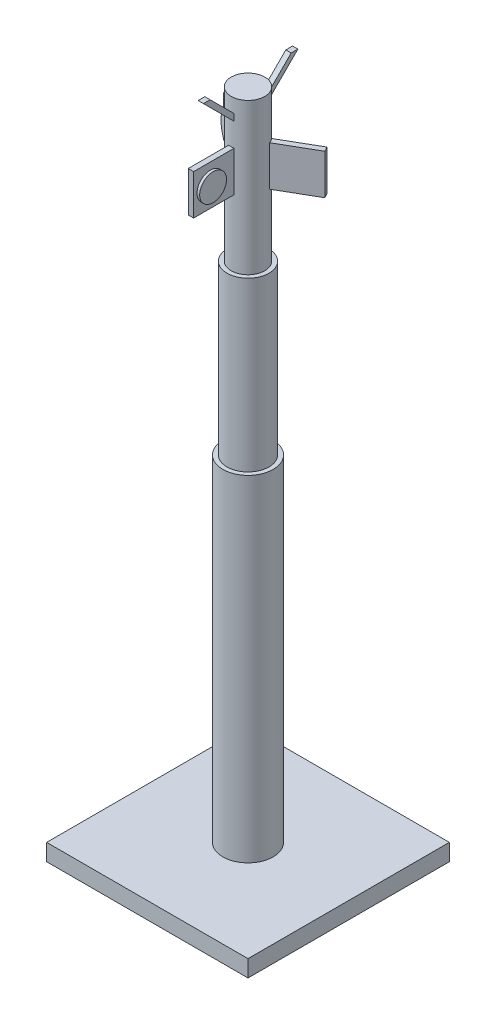
from build123d import *

# Parameters (mm, degrees)
SKETCH1_R                  = 7.5
BOSS_EXTRUDE1_DEPTH        = 100
SKETCH2_R                  = 6.25
BOSS_EXTRUDE2_DEPTH        = 50
SKETCH3_W                  = 60
SKETCH3_H                  = 60
BOSS_EXTRUDE3_DEPTH        = 5
SKETCH4_R                  = 5
BOSS_EXTRUDE4_DEPTH        = 45
BOSS_EXTRUDE5_DEPTH        = 0.8
SKETCH6_R                  = 4
BOSS_EXTRUDE6_DEPTH        = 0.8
CIRPATTERN2_COUNT          = 3
BOSS_EXTRUDE7_DEPTH        = 0.8
BOSS_EXTRUDE7_DEPTH_BACK   = 0.8
BOSS_EXTRUDE7_2_DEPTH      = 0.8
BOSS_EXTRUDE7_2_DEPTH_BACK = 0.8


with BuildPart() as part:
    # Sketch1 → Boss-Extrude1 (new body)
    with BuildSketch(Plane(origin=(0, 0, 0), x_dir=(1, 0, 0), z_dir=(0, 1, 0))):
        Circle(SKETCH1_R)
    extrude(amount=BOSS_EXTRUDE1_DEPTH)

    # Sketch2 → Boss-Extrude2 (add)
    with BuildSketch(Plane(origin=(0, 100, 0), x_dir=(1, 0, 0), z_dir=(0, 1, 0))):
        Circle(SKETCH2_R)
    extrude(amount=BOSS_EXTRUDE2_DEPTH)

    # Sketch3 → Boss-Extrude3 (add)
    with BuildSketch(Plane.XZ):
        Rectangle(SKETCH3_W, SKETCH3_H)
    extrude(amount=BOSS_EXTRUDE3_DEPTH)

    # Sketch4 → Boss-Extrude4 (add)
    with BuildSketch(Plane(origin=(0, 150, 0), x_dir=(1, 0, 0), z_dir=(0, 1, 0))):
        Circle(SKETCH4_R)
    extrude(amount=BOSS_EXTRUDE4_DEPTH)

    # Sketch5 → Boss-Extrude5 (add, symmetric)
    with BuildSketch(Plane(origin=(0, 0, 0), x_dir=(0, 0, -1), z_dir=(1, 0, 0))):
        Polygon((-5, 182), (-17, 182), (-17, 170), (-5, 170), (-2.5, 170), (-2.5, 182), align=None)
    boss_extrude5 = extrude(amount=BOSS_EXTRUDE5_DEPTH, both=True)

    # Sketch6 → Boss-Extrude6 (add)
    with BuildSketch(Plane(origin=(0.8, 0, 0), x_dir=(0, 0, -1), z_dir=(1, 0, 0))):
        with Locations((-12, 175.874664873)):
            Circle(SKETCH6_R)
    boss_extrude6 = extrude(amount=BOSS_EXTRUDE6_DEPTH)

    # CirPattern2: Boss-Extrude5, Boss-Extrude6 ×3 about axis
    cirpattern2_axis = Axis((0, 195, 0), (0, 1, 0))
    add([boss_extrude5.rotate(cirpattern2_axis, i * 360 / CIRPATTERN2_COUNT) for i in range(1, CIRPATTERN2_COUNT)])
    add([boss_extrude6.rotate(cirpattern2_axis, i * 360 / CIRPATTERN2_COUNT) for i in range(1, CIRPATTERN2_COUNT)])


with BuildPart() as body_2:
    # Sketch7 → Boss-Extrude7 (new, two sides: drawn at the far end of the back side and taken through both)
    with BuildSketch(Plane(origin=(0, 0, 0), x_dir=(0, 0, -1), z_dir=(1, 0, 0)).offset(-BOSS_EXTRUDE7_DEPTH_BACK)):
        Polygon((-0.622477317, 186.622477317), (-12.071067812, 198.071067812), (-14.071067812, 198.071067812), (-1.622477317, 185.622477317), align=None)
    extrude(amount=BOSS_EXTRUDE7_DEPTH + BOSS_EXTRUDE7_DEPTH_BACK)


with BuildPart() as body_3:
    # Sketch7 → Boss-Extrude7 2 (new, two sides: drawn at the far end of the back side and taken through both)
    with BuildSketch(Plane(origin=(0, 0, 0), x_dir=(0, 0, -1), z_dir=(1, 0, 0)).offset(-BOSS_EXTRUDE7_2_DEPTH_BACK)):
        Polygon((12.071067812, 198.071067812), (0.622477317, 186.622477317), (1.622477317, 185.622477317), (14.071067812, 198.071067812), align=None)
    extrude(amount=BOSS_EXTRUDE7_2_DEPTH + BOSS_EXTRUDE7_2_DEPTH_BACK)


solid = Compound([part.part, body_2.part, body_3.part])
